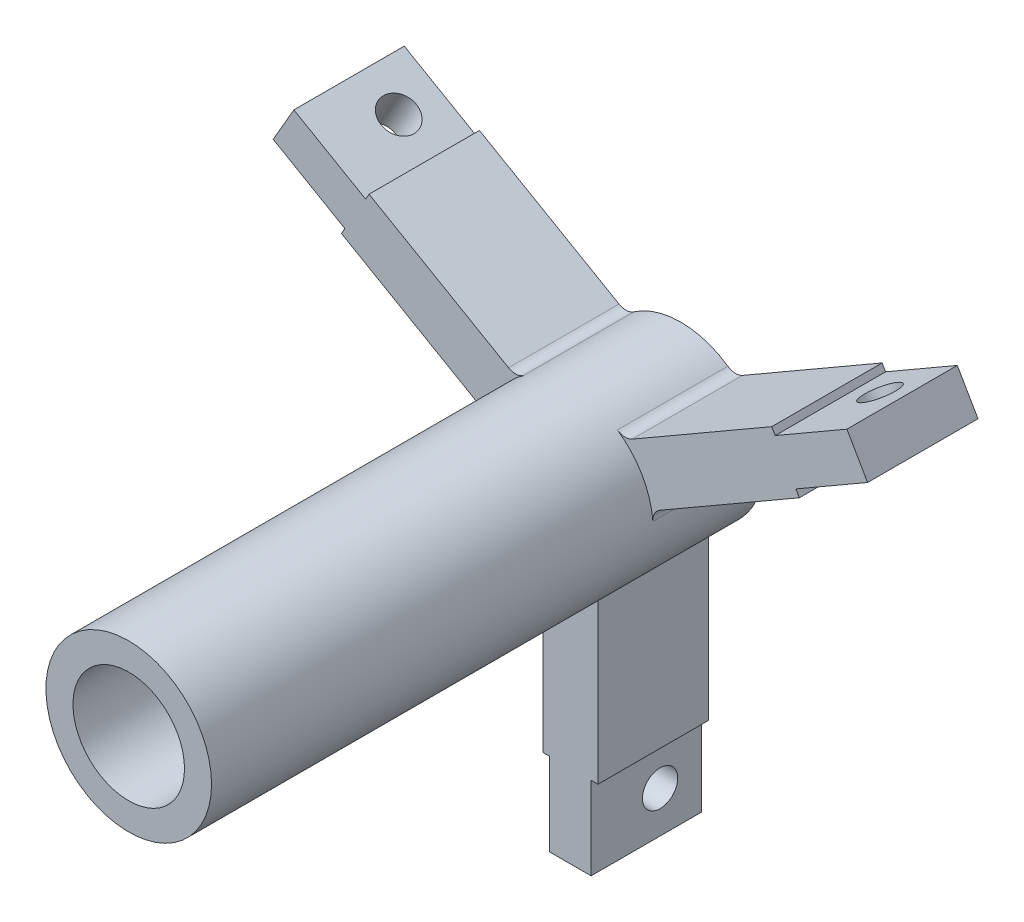
from build123d import *

# Parameters (mm, degrees)
SKETCH1_R           = 19.05
SKETCH1_R_2         = 12.827
BASE_EXTRUDE_DEPTH  = 127
SKETCH2_W           = 9.525
SKETCH2_H           = 25.4
BOSS_EXTRUDE1_DEPTH = 57.754917
SKETCH3_R           = 4.064
CUT_EXTRUDE1_DEPTH  = 24.8125
CIRPATTERN1_COUNT   = 3
SKETCH6_R           = 4.064
CUT_EXTRUDE2_DEPTH  = 76.516135768
SKETCH7_R           = 4.064
CUT_EXTRUDE3_DEPTH  = 76.516135768
SKETCH10_R          = 7.1501
CUT_EXTRUDE4_DEPTH  = 0.635
SKETCH13_W          = 12.7
SKETCH13_H          = 25.4
BOSS_EXTRUDE3_DEPTH = 39.189488
CIRPATTERN2_COUNT   = 3
FILLET1_R           = 3.175
FILLET2_R           = 3.175
FILLET3_R           = 3.175


with BuildPart() as part:
    # Sketch1 → Base-Extrude (new body)
    with BuildSketch(Plane.XY):
        Circle(SKETCH1_R)
        Circle(SKETCH1_R_2, mode=Mode.SUBTRACT)
    extrude(amount=BASE_EXTRUDE_DEPTH)

    # Sketch2 → Boss-Extrude1 (add)
    with BuildSketch(Plane(origin=(0, -76.2, 0), x_dir=(-1, 0, 0), z_dir=(0, 1, 0))):
        with Locations((0, 12.7)):
            Rectangle(SKETCH2_W, SKETCH2_H)
    boss_extrude1 = extrude(amount=BOSS_EXTRUDE1_DEPTH)

    # Sketch3 → Cut-Extrude1 (cut, through all)
    with BuildSketch(Plane.ZY.offset(4.7625)):
        with Locations((9.525, -66.675)):
            Circle(SKETCH3_R)
    extrude(amount=-CUT_EXTRUDE1_DEPTH, mode=Mode.SUBTRACT)

    # CirPattern1: Boss-Extrude1 ×3 about axis
    cirpattern1_axis = Axis((0, 0, 0), (0, 0, 1))
    for i in range(1, CIRPATTERN1_COUNT):
        add(boss_extrude1.rotate(cirpattern1_axis, i * 360 / CIRPATTERN1_COUNT))

    # Sketch6 → Cut-Extrude2 (cut, through all)
    with BuildSketch(Plane(origin=(-45.618861607, 20.838800715, 50.936831184), x_dir=(0.866025404, -0.5, 0), z_dir=(-0.5, -0.866025404, 0))):
        with Locations((-16.748506599, -41.411831184)):
            Circle(SKETCH6_R)
    extrude(amount=-CUT_EXTRUDE2_DEPTH, mode=Mode.SUBTRACT)

    # Sketch7 → Cut-Extrude3 (cut, through all)
    with BuildSketch(Plane(origin=(34.377585278, 14.3486468, 49.693003082), x_dir=(0.866025404, 0.5, 0), z_dir=(0.5, -0.866025404, 0))):
        with Locations((29.728814428, -40.168003082)):
            Circle(SKETCH7_R)
    extrude(amount=-CUT_EXTRUDE3_DEPTH, mode=Mode.SUBTRACT)

    # Sketch10 → Cut-Extrude4 (cut)
    with BuildSketch(Plane(origin=(0, 15.875, 0), x_dir=(-1, 0, 0), z_dir=(0, 1, 0))):
        with Locations((0, 38.1)):
            Circle(SKETCH10_R)
    extrude(amount=-CUT_EXTRUDE4_DEPTH, mode=Mode.SUBTRACT)

    # Sketch12 → Hole2 (revolve, cut)
    with BuildSketch(Plane(origin=(0, 15.24, 38.1), x_dir=(0, 0, 1), z_dir=(1, 0, 0))):
        Polygon((0, 0), (0, 14.233804302), (2.552697789, 12.699989), (2.552697789, 9.52499175), (3.17499725, 9.52499175), (3.17499725, 0.002539998), (3.17499725, 0), align=None)
    revolve(axis=Axis((0, 15.24, 38.1), (0, -1, 0)), mode=Mode.SUBTRACT)

    # Sketch13 → Boss-Extrude3 (add)
    with BuildSketch(Plane(origin=(0, -57.15, 0), x_dir=(-1, 0, 0), z_dir=(0, 1, 0))):
        with Locations((0, 12.7)):
            Rectangle(SKETCH13_W, SKETCH13_H)
    boss_extrude3 = extrude(amount=BOSS_EXTRUDE3_DEPTH)

    # CirPattern2: Boss-Extrude3 ×3 about axis
    cirpattern2_axis = Axis((0, 0, 0), (0, 0, 1))
    for i in range(1, CIRPATTERN2_COUNT):
        add(boss_extrude3.rotate(cirpattern2_axis, i * 360 / CIRPATTERN2_COUNT))

    # Fillet1
    fillet1_edges = [part.edges().sort_by_distance(p)[0] for p in [
        (-12.379259657, 14.479517314, 12.7),
        (12.379259657, 14.479517314, 12.7),
    ]]
    fillet(fillet1_edges, radius=FILLET1_R)

    # Fillet2
    fillet2_edges = [part.edges().sort_by_distance(p)[0] for p in [
        (-18.729259657, 3.480994686, 12.7),
        (-6.35, -17.960512, 12.7),
    ]]
    fillet(fillet2_edges, radius=FILLET2_R)

    # Fillet3
    fillet3_edges = [part.edges().sort_by_distance(p)[0] for p in [
        (18.729259657, 3.480994686, 12.7),
        (6.35, -17.960512, 12.7),
    ]]
    fillet(fillet3_edges, radius=FILLET3_R)


solid = part.part
